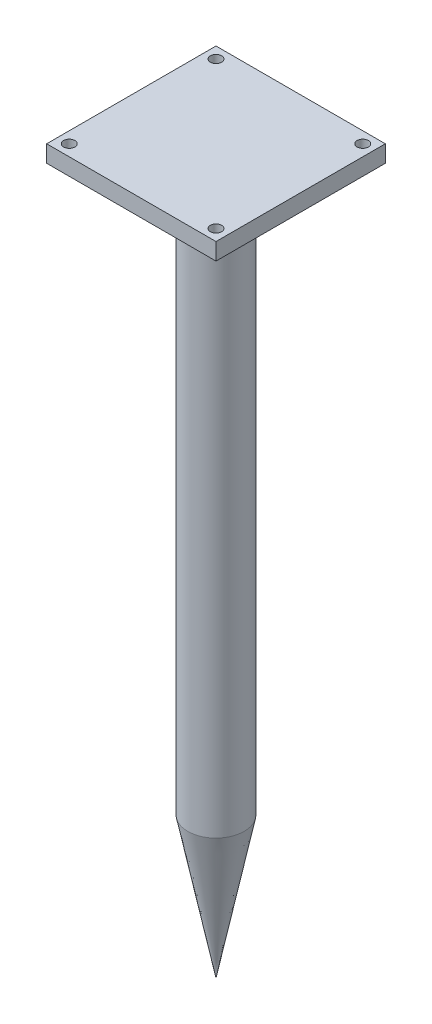
from build123d import *

# Parameters (mm, degrees)
SKETCH1_R           = 5
BOSS_EXTRUDE1_DEPTH = 100
SKETCH3_W           = 30
SKETCH3_H           = 30
BOSS_EXTRUDE3_DEPTH = 3
SKETCH4_R           = 1
CUT_EXTRUDE1_DEPTH  = 3


with BuildPart() as part:
    # Sketch1 → Boss-Extrude1 (new body)
    with BuildSketch(Plane(origin=(0, 0, 0), x_dir=(1, 0, 0), z_dir=(0, 1, 0))):
        Circle(SKETCH1_R)
    extrude(amount=BOSS_EXTRUDE1_DEPTH)

    # Sketch3 → Boss-Extrude3 (add)
    with BuildSketch(Plane(origin=(0, 100, 0), x_dir=(1, 0, 0), z_dir=(0, 1, 0))):
        Rectangle(SKETCH3_W, SKETCH3_H)
    extrude(amount=BOSS_EXTRUDE3_DEPTH)

    # Sketch4 → Cut-Extrude1 (cut)
    with BuildSketch(Plane(origin=(0, 103, 0), x_dir=(1, 0, 0), z_dir=(0, 1, 0))):
        with Locations((-13, 13)):
            Circle(SKETCH4_R)
        with Locations((13, 13)):
            Circle(SKETCH4_R)
        with Locations((13, -13)):
            Circle(SKETCH4_R)
        with Locations((-13, -13)):
            Circle(SKETCH4_R)
    extrude(amount=-CUT_EXTRUDE1_DEPTH, mode=Mode.SUBTRACT)

    # Sketch5 → Revolve1 (revolve)
    with BuildSketch(Plane(origin=(0, 0, 0), x_dir=(0, 0, -1), z_dir=(1, 0, 0))):
        Polygon((0, 0), (0, -25), (5, 0), align=None)
    revolve(axis=Axis((0, 0, 0), (0, -1, 0)))


solid = part.part
